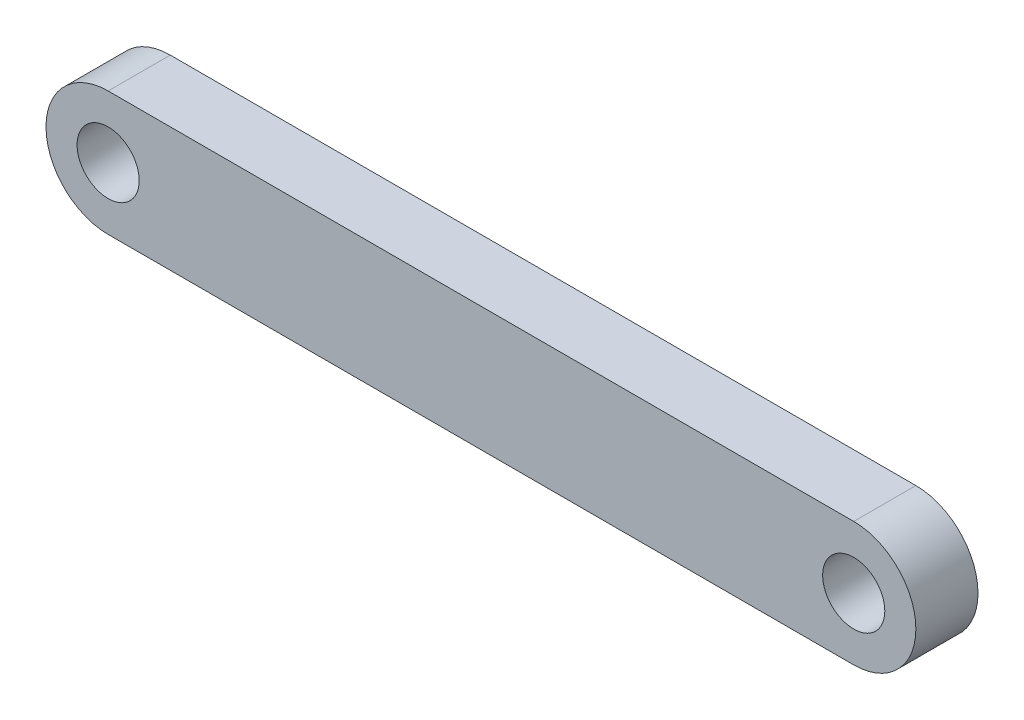
from build123d import *

# Parameters (mm, degrees)
SKETCH1_R        = 3.175
EXTRUSION1_DEPTH = 6.35


with BuildPart() as part:
    # Sketch1 → Extrusion1 (new body)
    with BuildSketch(Plane.XY):
        with BuildLine():
            Line((0, 0), (76.2, 0))
            ThreePointArc((76.2, 0), (82.55, 6.35), (76.2, 12.7))
            Line((76.2, 12.7), (0, 12.7))
            ThreePointArc((0, 12.7), (-6.35, 6.35), (0, 0))
        make_face()
        with Locations((76.2, 6.35)):
            Circle(SKETCH1_R, mode=Mode.SUBTRACT)
        with Locations((0, 6.35)):
            Circle(SKETCH1_R, mode=Mode.SUBTRACT)
    extrude(amount=EXTRUSION1_DEPTH)


solid = part.part
